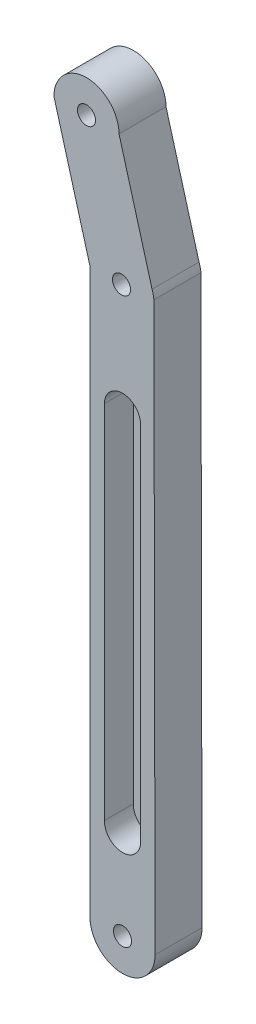
from build123d import *

# Parameters (mm, degrees)
SKETCH1_R      = 2.5
EXTRUDE1_DEPTH = 13
EXTRUDE2_DEPTH = 8


with BuildPart() as part:
    # Sketch1 → Extrude1 (new body)
    with BuildSketch(Plane.XY):
        with BuildLine():
            Line((-11.114615619, 113.277430864), (-11.114615619, -42.636308558))
            ThreePointArc((-11.114615619, -42.636308558), (-2.114615619, -51.636308558), (6.885384381, -42.636308558))
            Line((6.885384381, -42.636308558), (6.565118116, 114.072785693))
            ThreePointArc((6.565118116, 114.072785693), (6.384581051, 115.236243879), (6.053710916, 116.36617907))
            Line((6.053710916, 116.36617907), (-3.084934036, 148.987312466))
            ThreePointArc((-3.084934036, 148.987312466), (-12.084934036, 157.987312466), (-21.084934036, 148.987312466))
            Line((-21.084934036, 148.987312466), (-11.114615619, 113.277430864))
        make_face()
        with Locations((-2.399669149, 113.277430864)):
            Circle(SKETCH1_R, mode=Mode.SUBTRACT)
        with Locations((-2.114615619, -42.636308558)):
            Circle(SKETCH1_R, mode=Mode.SUBTRACT)
        with Locations((-12.084934036, 148.987312466)):
            Circle(SKETCH1_R, mode=Mode.SUBTRACT)
    extrude(amount=EXTRUDE1_DEPTH)

    # Sketch2 → Extrude2 (cut)
    with BuildSketch(Plane.XY.offset(13)):
        with BuildLine():
            Line((2.885384381, 82.363691442), (2.828618024, -16.885015572))
            ThreePointArc((2.828618024, -16.885015572), (-1.817326792, -22.627462668), (-7.112080712, -17.477114833))
            Line((-7.112080712, -17.477114833), (-7.114615619, 82.363691442))
            ThreePointArc((-7.114615619, 82.363691442), (-2.114615619, 87.363691442), (2.885384381, 82.363691442))
        make_face()
    extrude(amount=-EXTRUDE2_DEPTH, mode=Mode.SUBTRACT)


solid = part.part
